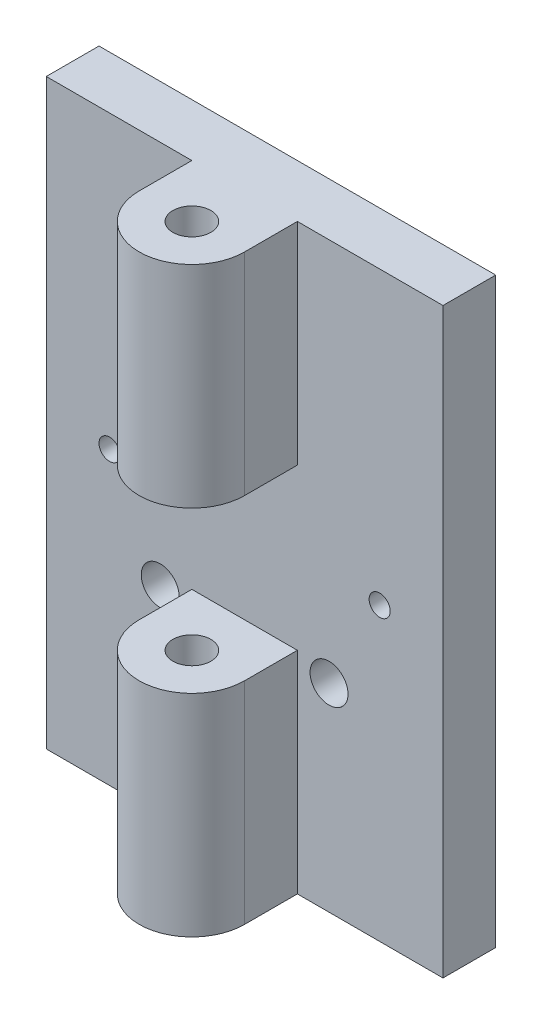
from build123d import *

# Parameters (mm, degrees)
SKETCH2_W           = 23.876
SKETCH2_H           = 35.052
SKETCH2_R           = 1.143
SKETCH2_R_2         = 0.635
BOSS_EXTRUDE1_DEPTH = 3.175
SKETCH3_W           = 6.35
SKETCH3_H           = 35.052
BOSS_EXTRUDE2_DEPTH = 6.35
SKETCH4_R           = 1.143
CUT_EXTRUDE3_DEPTH  = 49.53
SKETCH5_W           = 6.35
SKETCH5_H           = 9.652
CUT_EXTRUDE4_DEPTH  = 24.765
CUT_EXTRUDE5_DEPTH  = 49.53


with BuildPart() as part:
    # Sketch2 → Boss-Extrude1 (new body)
    with BuildSketch(Plane.XY):
        with Locations((0, 17.526)):
            Rectangle(SKETCH2_W, SKETCH2_H)
        with Locations((-5.08, 11.938)):
            Circle(SKETCH2_R, mode=Mode.SUBTRACT)
        with Locations((5.08, 11.938)):
            Circle(SKETCH2_R, mode=Mode.SUBTRACT)
        with Locations((-8.128, 17.526)):
            Circle(SKETCH2_R_2, mode=Mode.SUBTRACT)
        with Locations((8.128, 17.526)):
            Circle(SKETCH2_R_2, mode=Mode.SUBTRACT)
    extrude(amount=BOSS_EXTRUDE1_DEPTH)

    # Sketch3 → Boss-Extrude2 (add)
    with BuildSketch(Plane.XY.offset(3.175)):
        with Locations((0, 17.526)):
            Rectangle(SKETCH3_W, SKETCH3_H)
    extrude(amount=BOSS_EXTRUDE2_DEPTH)

    # Sketch4 → Cut-Extrude3 (cut)
    with BuildSketch(Plane(origin=(0, 0, 0), x_dir=(1, 0, 0), z_dir=(0, 1, 0))):
        with Locations((0, -6.35)):
            Circle(SKETCH4_R)
    extrude(amount=CUT_EXTRUDE3_DEPTH, mode=Mode.SUBTRACT)

    # Sketch5 → Cut-Extrude4 (cut, symmetric)
    with BuildSketch(Plane(origin=(0, 0, 0), x_dir=(0, 0, -1), z_dir=(1, 0, 0))):
        with Locations((-6.35, 17.526)):
            Rectangle(SKETCH5_W, SKETCH5_H)
    extrude(amount=CUT_EXTRUDE4_DEPTH, both=True, mode=Mode.SUBTRACT)

    # Sketch6 → Cut-Extrude5 (cut)
    with BuildSketch(Plane(origin=(0, 0, 0), x_dir=(1, 0, 0), z_dir=(0, 1, 0))):
        with BuildLine():
            ThreePointArc((0, -9.525), (-2.24506403, -8.59506403), (-3.175, -6.35))
            Line((-3.175, -6.35), (-3.175, -9.525))
            Line((-3.175, -9.525), (0, -9.525))
        make_face()
        with BuildLine():
            ThreePointArc((3.175, -6.35), (2.24506403, -8.59506403), (0, -9.525))
            Line((0, -9.525), (3.175, -9.525))
            Line((3.175, -9.525), (3.175, -6.35))
        make_face()
    extrude(amount=CUT_EXTRUDE5_DEPTH, mode=Mode.SUBTRACT)


solid = part.part
